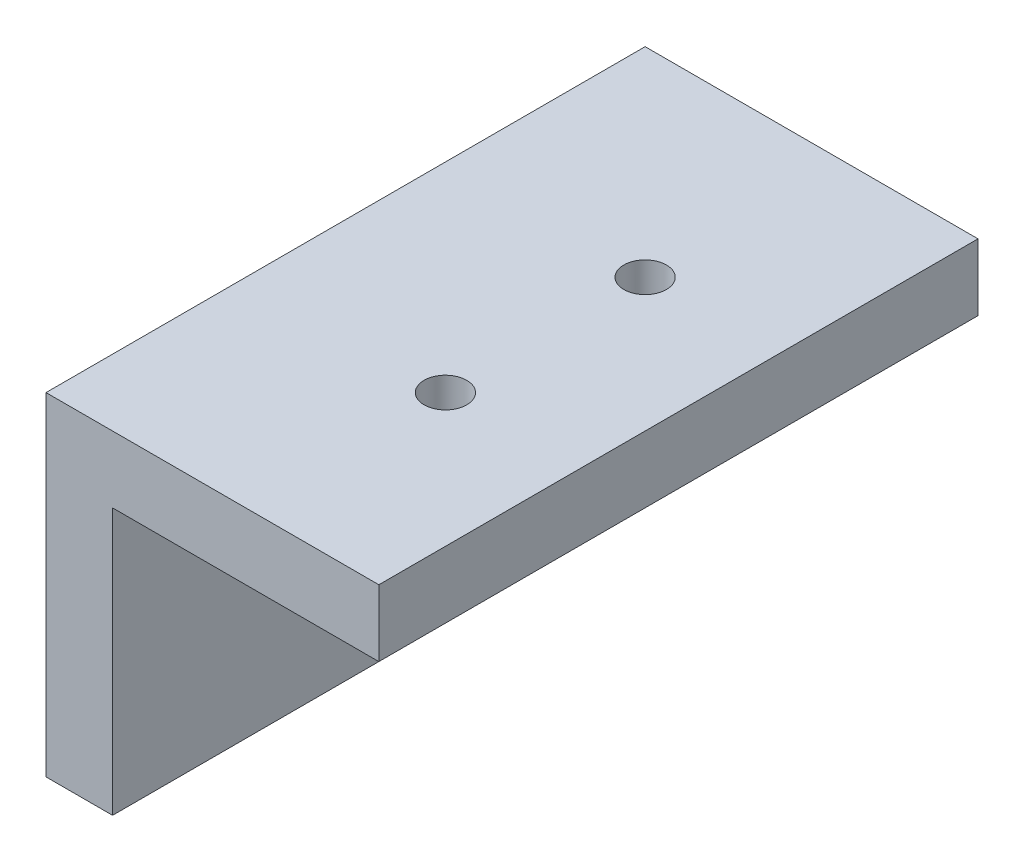
from build123d import *

# Parameters (mm, degrees)
BOSS_EXTRUDE1_DEPTH = 45
CUT_EXTRUDE1_REACH  = 7
SKETCH2_R           = 1.6
CUT_EXTRUDE2_REACH  = 7
SKETCH3_R           = 1.6
CUT_EXTRUDE3_START  = -1.25
CUT_EXTRUDE3_DEPTH  = 2.5


with BuildPart() as part:
    # Sketch1 → Boss-Extrude1 (new body)
    with BuildSketch(Plane.XY):
        Polygon((0, 0), (0, -20), (-5, -20), (-5, 5), (20, 5), (20, 0), align=None)
    extrude(amount=BOSS_EXTRUDE1_DEPTH)

    # Sketch2 → Cut-Extrude1 (cut, up to next)
    with BuildSketch(Plane(origin=(0, 0, 0), x_dir=(0, 0, -1), z_dir=(1, 0, 0)), mode=Mode.PRIVATE) as cut_extrude1_sk1:
        with Locations((-30, -10)):
            Circle(SKETCH2_R)
    cut_extrude1_tool1 = extrude(cut_extrude1_sk1.sketch, amount=-CUT_EXTRUDE1_REACH, mode=Mode.PRIVATE) & part.part
    add(cut_extrude1_tool1.solids().sort_by_distance((0, -10, 30))[0], mode=Mode.SUBTRACT)
    # Sketch2 → Cut-Extrude1 (cut, up to next)
    with BuildSketch(Plane(origin=(0, 0, 0), x_dir=(0, 0, -1), z_dir=(1, 0, 0)), mode=Mode.PRIVATE) as cut_extrude1_sk2:
        with Locations((-15, -10)):
            Circle(SKETCH2_R)
    cut_extrude1_tool2 = extrude(cut_extrude1_sk2.sketch, amount=-CUT_EXTRUDE1_REACH, mode=Mode.PRIVATE) & part.part
    add(cut_extrude1_tool2.solids().sort_by_distance((0, -10, 15))[0], mode=Mode.SUBTRACT)

    # Sketch3 → Cut-Extrude2 (cut, up to next)
    with BuildSketch(Plane.XZ, mode=Mode.PRIVATE) as cut_extrude2_sk1:
        with Locations((10, 30)):
            Circle(SKETCH3_R)
    cut_extrude2_tool1 = extrude(cut_extrude2_sk1.sketch, amount=-CUT_EXTRUDE2_REACH, mode=Mode.PRIVATE) & part.part
    add(cut_extrude2_tool1.solids().sort_by_distance((10, 0, 30))[0], mode=Mode.SUBTRACT)
    # Sketch3 → Cut-Extrude2 (cut, up to next)
    with BuildSketch(Plane.XZ, mode=Mode.PRIVATE) as cut_extrude2_sk2:
        with Locations((10, 15)):
            Circle(SKETCH3_R)
    cut_extrude2_tool2 = extrude(cut_extrude2_sk2.sketch, amount=-CUT_EXTRUDE2_REACH, mode=Mode.PRIVATE) & part.part
    add(cut_extrude2_tool2.solids().sort_by_distance((10, 0, 15))[0], mode=Mode.SUBTRACT)

    # Sketch4 → Cut-Extrude3 (cut)
    with BuildSketch(Plane(origin=(0, 0, 0), x_dir=(0, 0, -1), z_dir=(1, 0, 0)).offset(CUT_EXTRUDE3_START)):
        Polygon((-30, -6.564765898), (-32.975, -8.282382949), (-32.975, -11.717617051), (-30, -13.435234102), (-27.025, -11.717617051), (-27.025, -8.282382949), align=None)
        Polygon((-15, -6.564765898), (-17.975, -8.282382949), (-17.975, -11.717617051), (-15, -13.435234102), (-12.025, -11.717617051), (-12.025, -8.282382949), align=None)
    extrude(amount=-CUT_EXTRUDE3_DEPTH, mode=Mode.SUBTRACT)


solid = part.part
